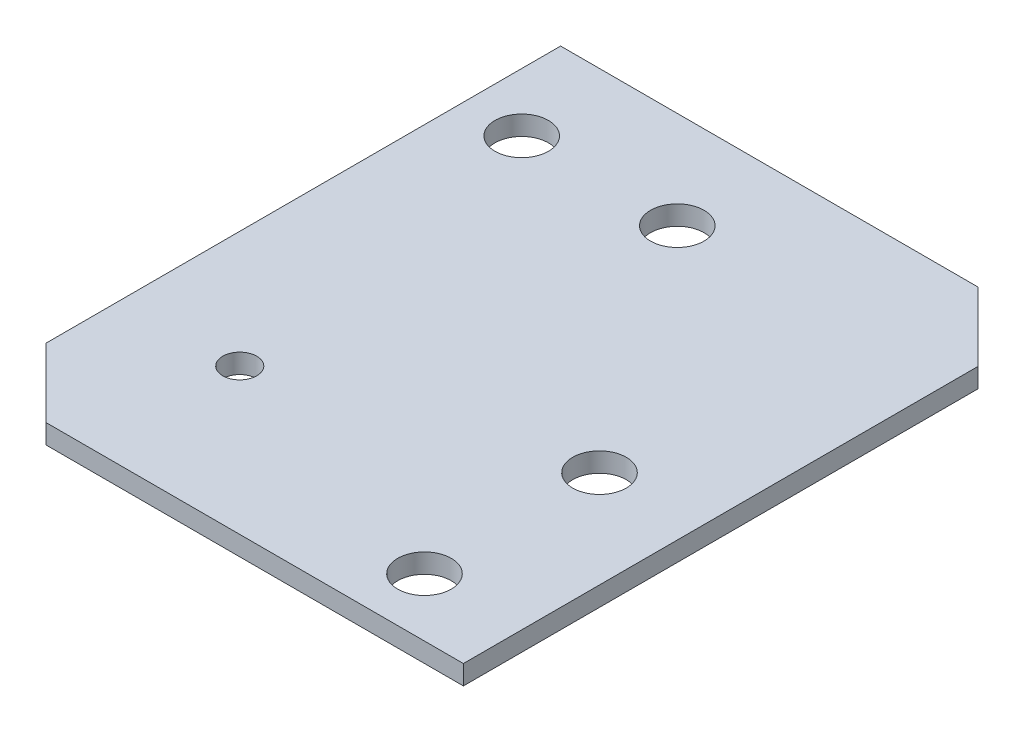
from build123d import *

# Parameters (mm, degrees)
SKETCH_1_W          = 50
SKETCH_1_H          = 60
EXTRUDE_1_DEPTH     = 2
SKETCH_2_R          = 2.75
SKETCH_2_R_2        = 1.75
CUT_EXTRUDE_1_DEPTH = 3


with BuildPart() as part:
    # 草图1 → 凸台-拉伸1 (new body)
    with BuildSketch(Plane(origin=(0, 0, 0), x_dir=(1, 0, 0), z_dir=(0, 1, 0))):
        with Locations((25, 30)):
            Rectangle(SKETCH_1_W, SKETCH_1_H)
    extrude(amount=EXTRUDE_1_DEPTH)

    # 草图2 → 切除-拉伸1 (cut, through all)
    with BuildSketch(Plane(origin=(0, 2, 0), x_dir=(1, 0, 0), z_dir=(0, 1, 0))):
        with Locations((6, 50)):
            Circle(SKETCH_2_R)
        with Locations((40, 6)):
            Circle(SKETCH_2_R)
        with Locations((12, 15)):
            Circle(SKETCH_2_R_2)
        with Locations((40, 24)):
            Circle(SKETCH_2_R)
        with Locations((22, 50)):
            Circle(SKETCH_2_R)
        Polygon((0, 7.071067812), (7.071067812, 0), (0, 0), align=None)
        Polygon((50, 60), (50, 52.928932188), (42.928932188, 60), align=None)
    extrude(amount=-CUT_EXTRUDE_1_DEPTH, mode=Mode.SUBTRACT)


solid = part.part
